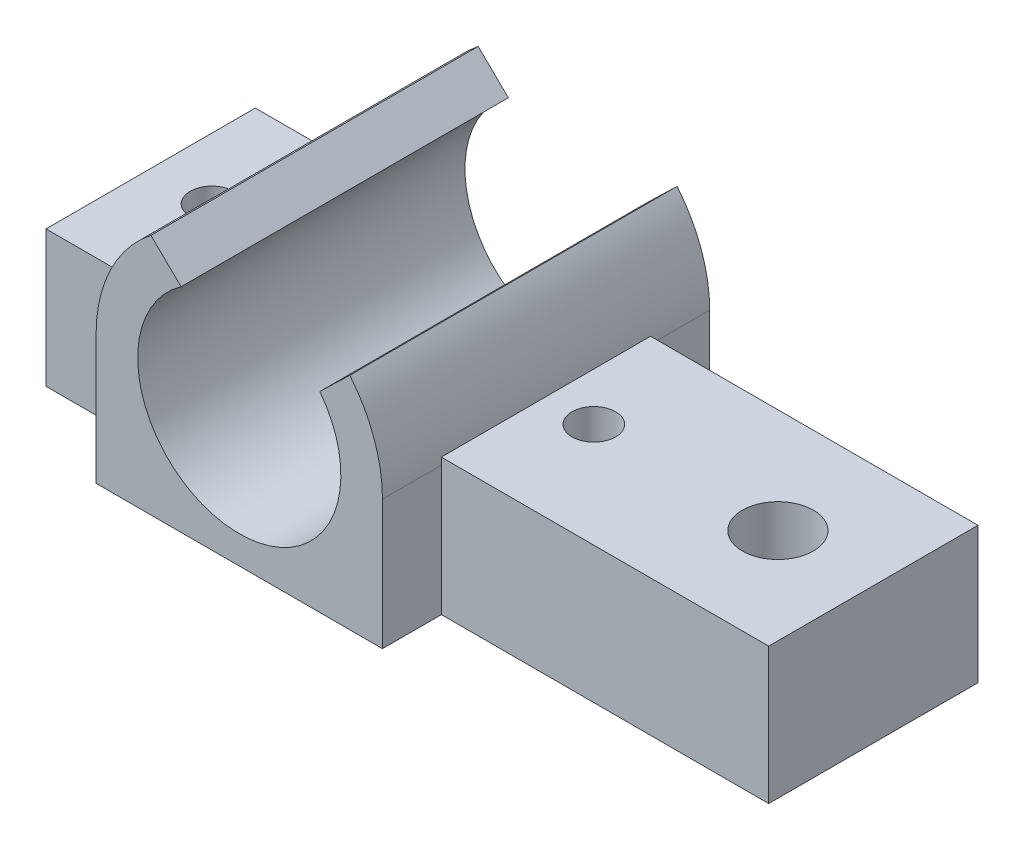
from build123d import *

# Parameters (mm, degrees)
SKETCH1_W                = 53
SKETCH1_H                = 15.35
SKETCH1_R                = 1.6
SKETCH1_R_2              = 2.6
BOSS_EXTRUDE1_DEPTH      = 10
BOSS_EXTRUDE2_DEPTH      = 4.325
BOSS_EXTRUDE2_DEPTH_BACK = 19.675
CUT_EXTRUDE1_DEPTH       = 20.675
CUT_EXTRUDE2_DEPTH       = 4
SKETCH5_R                = 2.6
BOSS_EXTRUDE3_DEPTH      = 0.4


with BuildPart() as part:
    # Sketch1 → Boss-Extrude1 (new body)
    with BuildSketch(Plane(origin=(0, 0, 0), x_dir=(1, 0, 0), z_dir=(0, 1, 0))):
        with Locations((46.893734614, 0)):
            Rectangle(SKETCH1_W, SKETCH1_H)
        with Locations((52.893734614, 0)):
            Circle(SKETCH1_R, mode=Mode.SUBTRACT)
        with Locations((24.893734614, 0)):
            Circle(SKETCH1_R, mode=Mode.SUBTRACT)
        with Locations((66.393734614, 0)):
            Circle(SKETCH1_R_2, mode=Mode.SUBTRACT)
    extrude(amount=BOSS_EXTRUDE1_DEPTH)

    # Sketch2 → Boss-Extrude2 (add, two sides)
    with BuildSketch(Plane(origin=(0, 0, -7.675), x_dir=(-1, 0, 0), z_dir=(0, 0, -1))) as boss_extrude2_sk:
        with BuildLine():
            Line((-44.801648562, 14.038617938), (-47.002272565, 16.170952878))
            ThreePointArc((-47.002272565, 16.170952878), (-48.777803829, 13.043328345), (-49.393734614, 9.5))
            Line((-49.393734614, 9.5), (-49.393734614, 0))
            Line((-49.393734614, 0), (-28.393734614, 0))
            Line((-28.393734614, 0), (-28.393734614, 9.5))
            ThreePointArc((-28.393734614, 9.5), (-29.451814157, 14.09348866), (-32.412808532, 17.761210391))
            Line((-32.412808532, 17.761210391), (-34.628407423, 15.608148979))
            ThreePointArc((-34.628407423, 15.608148979), (-37.757785789, 2.137111962), (-44.801648562, 14.038617938))
        make_face()
    extrude(amount=BOSS_EXTRUDE2_DEPTH)
    extrude(boss_extrude2_sk.sketch, amount=-BOSS_EXTRUDE2_DEPTH_BACK)

    # Sketch3 → Cut-Extrude1 (cut, through all)
    with BuildSketch(Plane.XY.offset(7.675)):
        with BuildLine():
            Line((46.326937154, 10), (31.460532075, 10))
            ThreePointArc((31.460532075, 10), (38.893734614, 2.05), (46.326937154, 10))
        make_face()
    extrude(amount=-CUT_EXTRUDE1_DEPTH, mode=Mode.SUBTRACT)

    # Sketch4 → Cut-Extrude2 (cut)
    with BuildSketch(Plane.XZ):
        Polygon((62.366716487, 2.325), (62.366716487, -2.325), (66.393734614, -4.65), (70.420752742, -2.325), (70.420752742, 2.325), (66.393734614, 4.65), align=None)
    extrude(amount=-CUT_EXTRUDE2_DEPTH, mode=Mode.SUBTRACT)

    # Sketch5 → Boss-Extrude3 (add)
    with BuildSketch(Plane.XZ.offset(-4)):
        with Locations((66.393734614, 0)):
            Circle(SKETCH5_R)
    extrude(amount=-BOSS_EXTRUDE3_DEPTH)


solid = part.part
